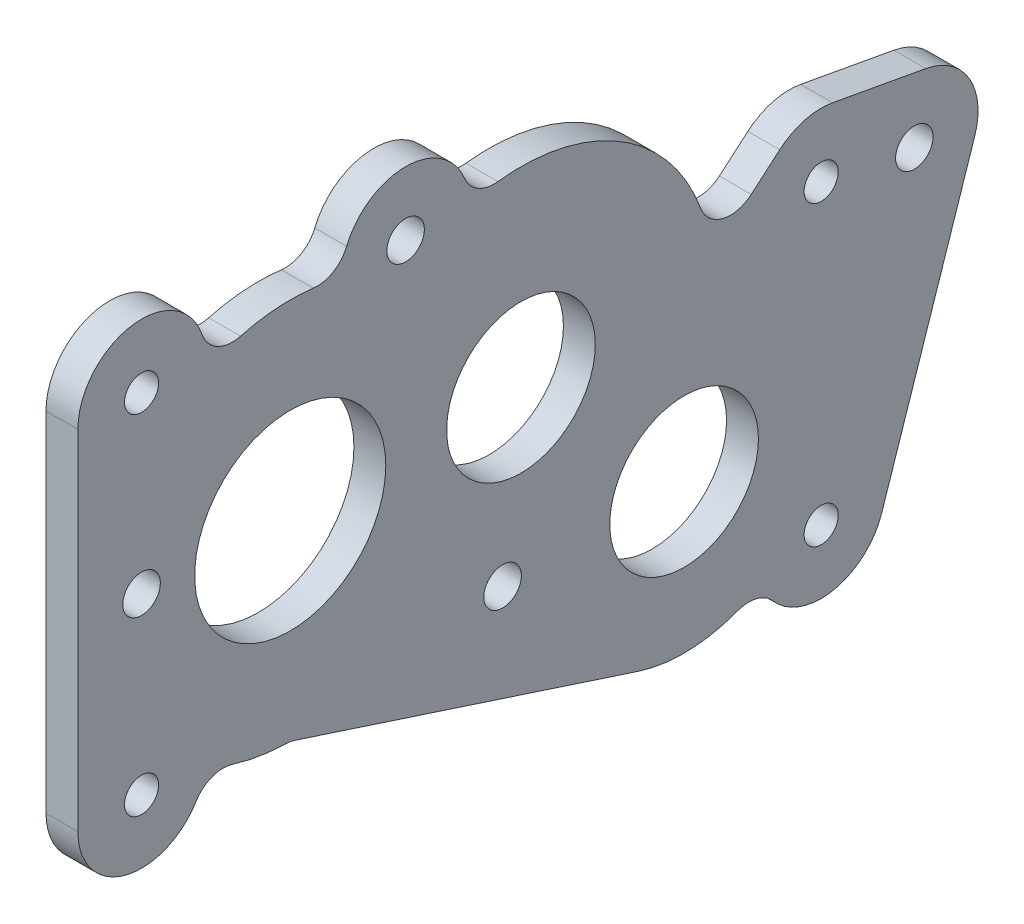
from build123d import *

# Parameters (mm, degrees)
SKETCH1_W              = 146.05
SKETCH1_H              = 101.6
BOSS_EXTRUDE2_DEPTH    = 4.7625
SKETCH2_R              = 11.1125
SKETCH2_R_2            = 14.2875
CUT_EXTRUDE1_DEPTH     = 5.7625
F_10_CLEARANCE_HOLE1_D = 5.1054
F_10_CLEARANCE_HOLE2_D = 5.6134
CUT_EXTRUDE2_DEPTH     = 5.7625
FILLET1_R              = 4.7625
SKETCH8_R              = 14.2875
CUT_EXTRUDE3_DEPTH     = 5.7625001
SKETCH9_R              = 14.2875
SKETCH9_R_2            = 11.1125
BOSS_EXTRUDE3_DEPTH    = 4.7625


with BuildPart() as part:
    # Sketch1 → Boss-Extrude2 (new body)
    with BuildSketch(Plane(origin=(0, 0, 0), x_dir=(0, 0, -1), z_dir=(1, 0, 0))):
        with Locations((73.025, 50.8)):
            Rectangle(SKETCH1_W, SKETCH1_H)
    extrude(amount=BOSS_EXTRUDE2_DEPTH)

    # Sketch2 → Cut-Extrude1 (cut, through all)
    with BuildSketch(Plane(origin=(4.7625, 0, 0), x_dir=(0, 0, -1), z_dir=(1, 0, 0))):
        with Locations((66.2432, 57.15)):
            Circle(SKETCH2_R)
        with Locations((31.75, 57.15)):
            Circle(SKETCH2_R)
        with Locations((90.633575625, 32.759624375)):
            Circle(SKETCH2_R_2)
    extrude(amount=-CUT_EXTRUDE1_DEPTH, mode=Mode.SUBTRACT)

    # #10 Clearance Hole1 (through all)
    with Locations(Plane(origin=(4.7625, 0, 0), x_dir=(0, 0, -1), z_dir=(1, 0, 0))):
        with Locations((9.525, 84.829624375), (111.125, 61.334624375), (9.525, 32.759624375), (111.125, 16.884624375)):
            Hole(F_10_CLEARANCE_HOLE1_D / 2)

    # #10 Clearance Hole2 (through all)
    with Locations(Plane(origin=(4.7625, 0, 0), x_dir=(0, 0, -1), z_dir=(1, 0, 0))):
        with Locations((9.525, 58.794624375), (48.9966, 84.829624375), (125.056959494, 58.794624375), (63.5, 32.759624375)):
            Hole(F_10_CLEARANCE_HOLE2_D / 2)

    # Sketch7 → Cut-Extrude2 (cut, through all)
    with BuildSketch(Plane(origin=(4.7625, 0, 0), x_dir=(0, 0, -1), z_dir=(1, 0, 0))):
        with BuildLine():
            ThreePointArc((58.52011675, 84.661535946), (82.426770011, 80.700428589), (94.694801926, 59.802729323))
            Line((94.694801926, 59.802729323), (104.928643901, 68.568627146))
            ThreePointArc((104.928643901, 68.568627146), (108.639710016, 70.529675147), (112.8333867, 70.705165442))
            Line((112.8333867, 70.705165442), (126.765346195, 68.165165442))
            ThreePointArc((126.765346195, 68.165165442), (133.252161891, 63.648929957), (134.095626133, 55.789939634))
            Line((134.095626133, 55.789939634), (120.163666639, 13.879939634))
            ThreePointArc((120.163666639, 13.879939634), (111.198276093, 7.359906237), (102.133632107, 13.741229966))
            ThreePointArc((102.133632107, 13.741229966), (93.170530223, 10.67989416), (83.746678665, 11.628574348))
            Line((83.746678665, 11.628574348), (31.75, 28.575))
            ThreePointArc((31.75, 28.575), (25.188529488, 29.338532406), (18.97770782, 31.588326004))
            ThreePointArc((18.97770782, 31.588326004), (8.938236412, 23.252714599), (0, 32.759624375))
            Line((0, 32.759624375), (0, 0))
            Line((0, 0), (146.05, 0))
            Line((146.05, 0), (146.05, 101.6))
            Line((146.05, 101.6), (0, 101.6))
            Line((0, 101.6), (0, 84.829624375))
            ThreePointArc((0, 84.829624375), (10.639110316, 94.28924293), (18.789371801, 82.616698681))
            ThreePointArc((18.789371801, 82.616698681), (28.938717529, 85.586373114), (39.47308325, 84.661535946))
            ThreePointArc((39.47308325, 84.661535946), (48.9966, 94.354624375), (58.52011675, 84.661535946))
        make_face()
    extrude(amount=-CUT_EXTRUDE2_DEPTH, mode=Mode.SUBTRACT)

    # Fillet1
    fillet1_edges = [part.edges().sort_by_distance(p)[0] for p in [
        (2.38125, 59.802729323, -94.694801926),
        (2.38125, 84.661535946, -58.52011675),
        (2.38125, 84.661535946, -39.47308325),
        (2.38125, 82.616698681, -18.789371801),
        (2.38125, 31.588326004, -18.97770782),
        (2.38125, 28.575, -31.75),
        (2.38125, 13.741229966, -102.133632107),
    ]]
    fillet(fillet1_edges, radius=FILLET1_R)

    # Sketch8 → Cut-Extrude3 (cut, through all)
    with BuildSketch(Plane(origin=(4.7625, 0, 0), x_dir=(0, 0, -1), z_dir=(1, 0, 0))):
        with Locations((31.75, 57.15)):
            Circle(SKETCH8_R)
    extrude(amount=-CUT_EXTRUDE3_DEPTH, mode=Mode.SUBTRACT)

    # Sketch9 → Boss-Extrude3 (add)
    with BuildSketch(Plane(origin=(4.7625, 0, 0), x_dir=(0, 0, -1), z_dir=(1, 0, 0))):
        with Locations((90.633575625, 32.759624375)):
            Circle(SKETCH9_R)
        with Locations((90.633575625, 32.759624375)):
            Circle(SKETCH9_R_2, mode=Mode.SUBTRACT)
    extrude(amount=-BOSS_EXTRUDE3_DEPTH)


solid = part.part
